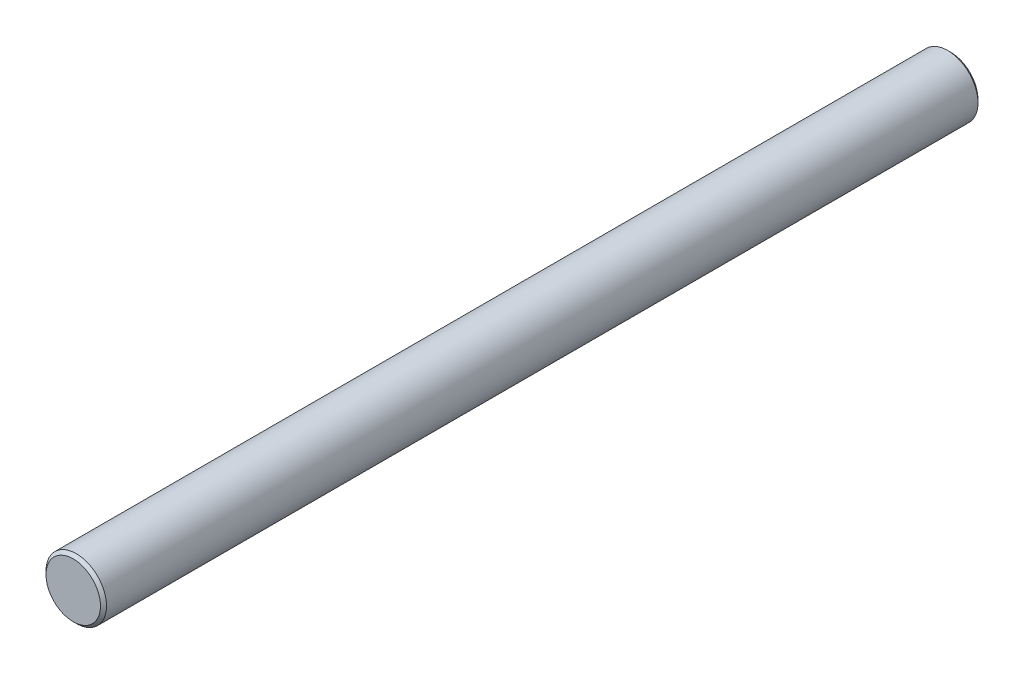
from build123d import *

# Parameters (mm, degrees)
SKETCH1_R           = 5
BOSS_EXTRUDE1_DEPTH = 145
CUT_EXTRUDE1_DEPTH  = 8
CHAMFER1_SIZE       = 0.5


with BuildPart() as part:
    # Sketch1 → Boss-Extrude1 (new body)
    with BuildSketch(Plane.XY):
        Circle(SKETCH1_R)
    extrude(amount=BOSS_EXTRUDE1_DEPTH)

    # Sketch2 → Cut-Extrude1 (cut)
    with BuildSketch(Plane(origin=(0, 0, 0), x_dir=(-1, 0, 0), z_dir=(0, 0, -1))):
        with BuildLine():
            Line((4, 3), (4, -3))
            ThreePointArc((4, -3), (5, 0), (4, 3))
        make_face()
    extrude(amount=-CUT_EXTRUDE1_DEPTH, mode=Mode.SUBTRACT)

    # Chamfer1
    chamfer1_edges = [part.edges().sort_by_distance(p)[0] for p in [
        (-5, 0, 145),
        (1.58113883, 4.74341649, 0),
    ]]
    chamfer(chamfer1_edges, length=CHAMFER1_SIZE)


solid = part.part
